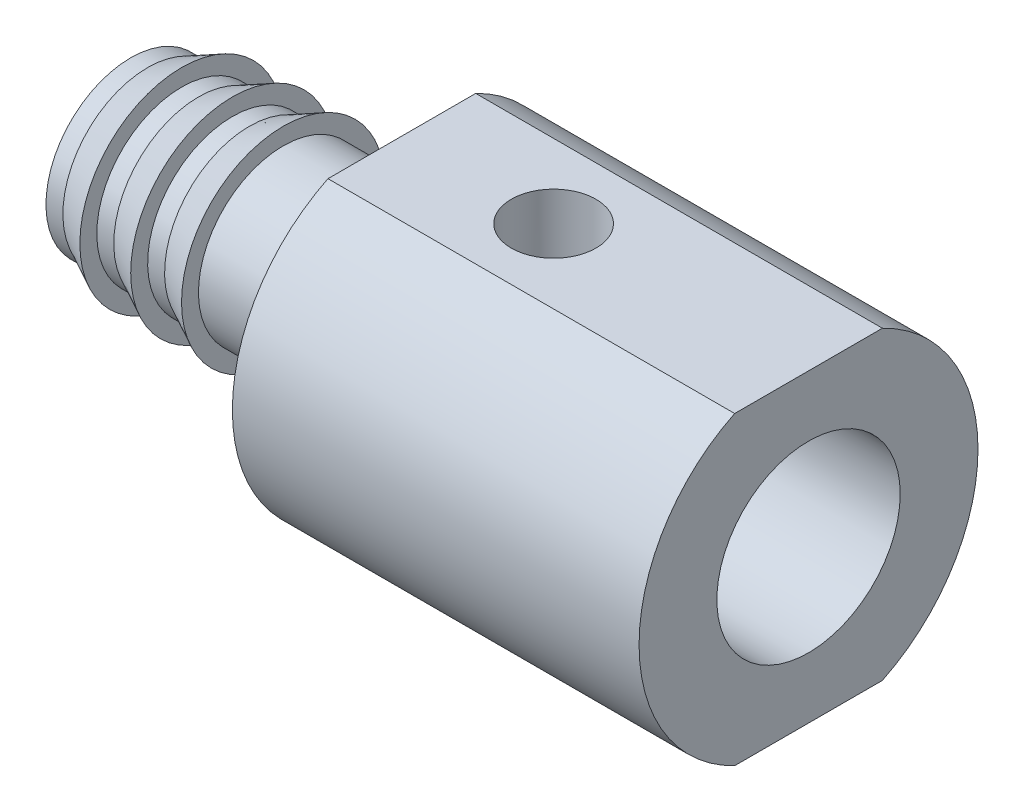
from build123d import *

# Parameters (mm, degrees)
SKETCH4_OUTSIDE_W           = 16.898
SKETCH4_OUTSIDE_H           = 16.898
SKETCH4_OUTSIDE_W_2         = 32
SKETCH4_OUTSIDE_H_2         = 9
CUT_EXTRUDE1_DEPTH          = 21
F_1_4_28_TAPPED_HOLE2_D     = 5.4102
F_1_4_28_TAPPED_HOLE2_DEPTH = 10
M3_TAPPED_HOLE1_D           = 2.5


with BuildPart() as part:
    # Sketch1 → Revolve1 (revolve)
    with BuildSketch(Plane.XY):
        Polygon((-1.315886695, -5.259279322), (-4.815886695, -5.259279322), (-4.815886695, -4.759279322), (-5.815886695, -5.259279322), (-6.315886695, -5.259279322), (-6.315886695, -4.759279322), (-7.315886695, -5.259279322), (-7.815886695, -5.259279322), (-7.815886695, -4.759279322), (-8.815886695, -5.259279322), (-9.315886695, -5.259279322), (-9.315886695, -5.759279322), (0.684113305, -5.759279322), (0.684113305, -7.759279322), (10.684113305, -7.759279322), (10.684113305, -2.759279322), (-1.315886695, -2.759279322), align=None)
    revolve(axis=Axis((2.271553965, -7.759279322, 0), (-1, 0, 0)))

    # Sketch4 outside → Cut-Extrude1 (cut, through all)
    with BuildSketch(Plane(origin=(10.684113305, 0, 0), x_dir=(0, 0, -1), z_dir=(1, 0, 0))):
        with Locations((0, -7.759)):
            Rectangle(SKETCH4_OUTSIDE_W, SKETCH4_OUTSIDE_H)
        with Locations((0, -7.759279322)):
            Rectangle(SKETCH4_OUTSIDE_W_2, SKETCH4_OUTSIDE_H_2, mode=Mode.SUBTRACT)
    extrude(amount=-CUT_EXTRUDE1_DEPTH, mode=Mode.SUBTRACT)

    # 1/4-28 Tapped Hole2
    with Locations(Plane(origin=(10.684113305, 0, 0), x_dir=(0, 0, -1), z_dir=(1, 0, 0))):
        with Locations((0, -7.759279322)):
            Hole(F_1_4_28_TAPPED_HOLE2_D / 2, depth=F_1_4_28_TAPPED_HOLE2_DEPTH)

    # M3 Tapped Hole1 (through all)
    with Locations(Plane(origin=(0, -3.259279322, 0), x_dir=(1, 0, 0), z_dir=(0, 1, 0))):
        with Locations((3.162442737, 0)):
            Hole(M3_TAPPED_HOLE1_D / 2)


solid = part.part
